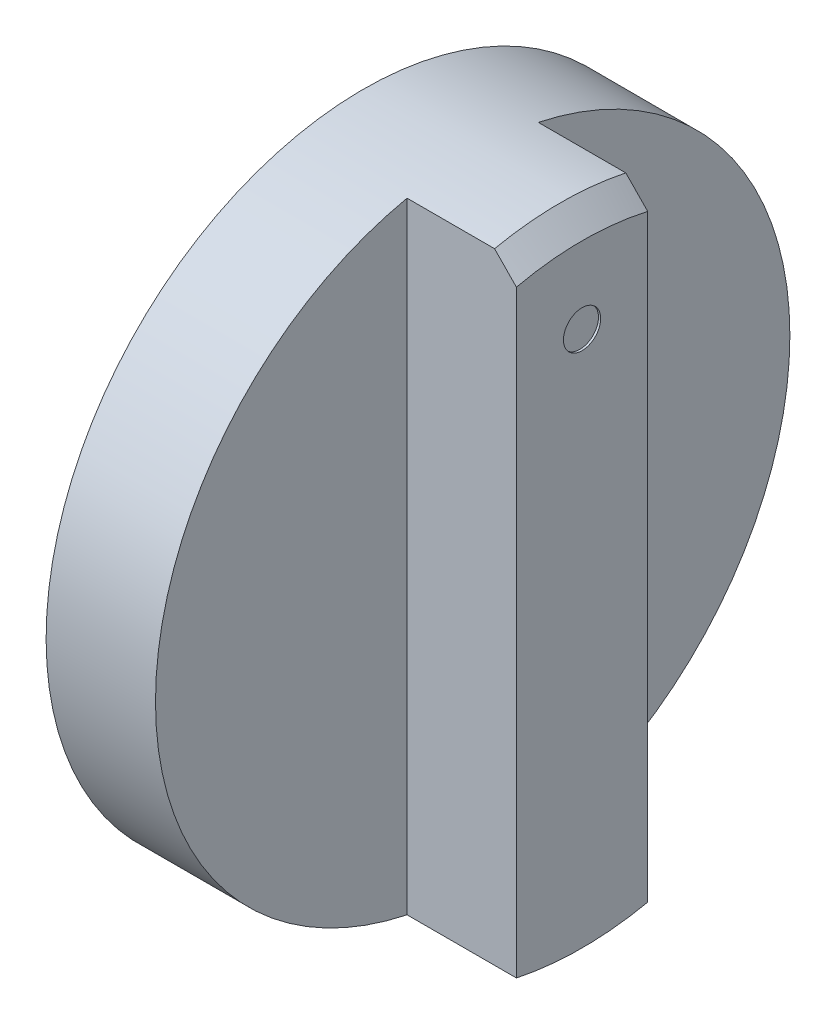
from build123d import *

# Parameters (mm, degrees)
SKETCH_1_R          = 14.5
EXTRUDE_1_DEPTH     = 5
EXTRUDE_2_DEPTH     = 5
CHAMFER_1_SIZE      = 1
SKETCH_3_R          = 0.85
CUT_EXTRUDE_1_DEPTH = 0.1


with BuildPart() as part:
    # 草图1 → 凸台-拉伸1 (new body)
    with BuildSketch(Plane(origin=(0, 0, 0), x_dir=(0, 0, -1), z_dir=(1, 0, 0))):
        Circle(SKETCH_1_R)
    extrude(amount=EXTRUDE_1_DEPTH)

    # 草图2 → 凸台-拉伸2 (add)
    with BuildSketch(Plane(origin=(5, 0, 0), x_dir=(0, 0, -1), z_dir=(1, 0, 0))):
        with BuildLine():
            ThreePointArc((3, 14.186260959), (1.508180397, 14.421351944), (4.2e-08, 14.5))
            ThreePointArc((4.2e-08, 14.5), (-1.508180355, 14.421351948), (-3, 14.186260959))
            Line((-3, 14.186260959), (-3, -14.186260959))
            ThreePointArc((-3, -14.186260959), (-1.508180376, -14.421351946), (0, -14.5))
            ThreePointArc((0, -14.5), (1.508180376, -14.421351946), (3, -14.186260959))
            Line((3, -14.186260959), (3, 14.186260959))
        make_face()
    extrude(amount=EXTRUDE_2_DEPTH)

    # 倒角1
    chamfer_1_edges = [part.edges().sort_by_distance(p)[0] for p in [
        (10, 14.5, 0),
    ]]
    chamfer(chamfer_1_edges, length=CHAMFER_1_SIZE)

    # 草图3 → 切除-拉伸1 (cut)
    with BuildSketch(Plane(origin=(10, 0, 0), x_dir=(0, 0, -1), z_dir=(1, 0, 0))):
        with Locations((0, 10)):
            Circle(SKETCH_3_R)
    extrude(amount=-CUT_EXTRUDE_1_DEPTH, mode=Mode.SUBTRACT)


solid = part.part
